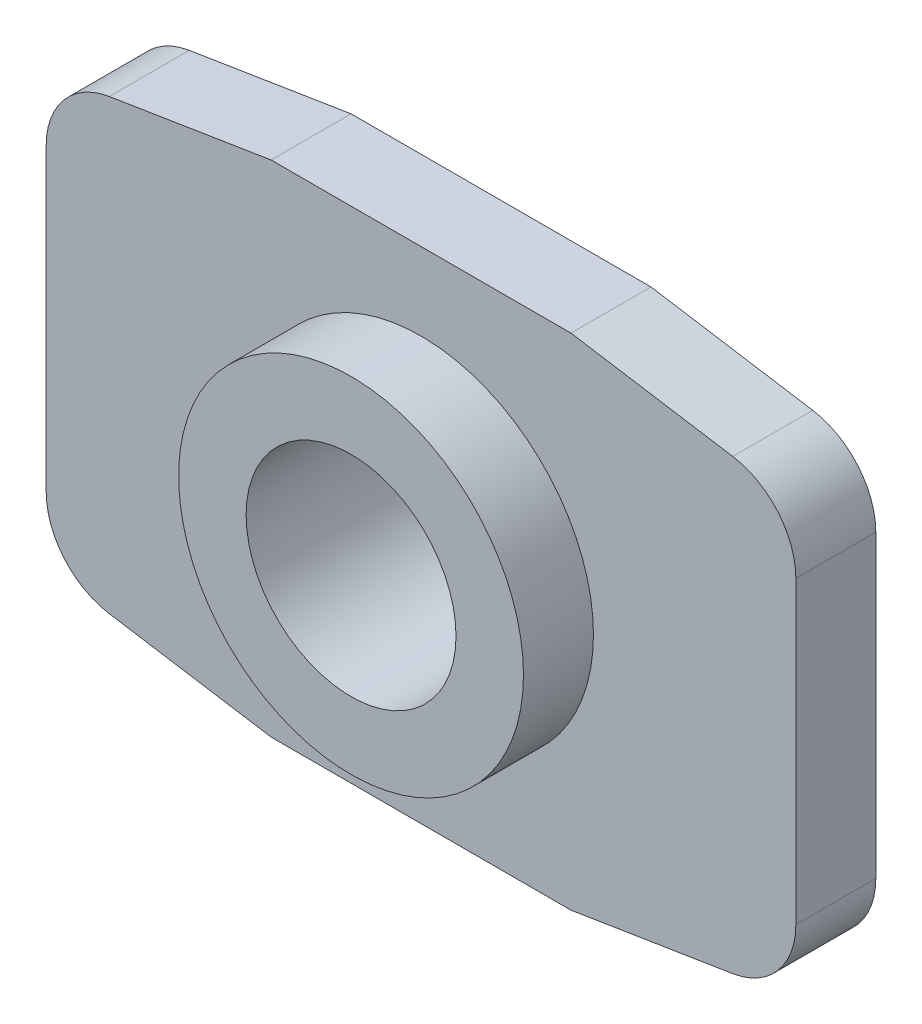
from build123d import *

# Parameters (mm, degrees)
BOSS_EXTRUDE1_DEPTH   = 1.6
SKETCH2_R             = 3.45
BOSS_EXTRUDE2_DEPTH   = 1.4
M5X0_8_TAPPED_HOLE1_D = 4.2


with BuildPart() as part:
    # Sketch1 → Boss-Extrude1 (new body)
    with BuildSketch(Plane.XY):
        with BuildLine():
            Line((-6.237396753, 4.481095129), (-3, 5))
            Line((-3, 5), (3, 5))
            Line((3, 5), (6.237396753, 4.481095129))
            ThreePointArc((6.237396753, 4.481095129), (7.141511088, 3.973114811), (7.5, 3))
            Line((7.5, 3), (7.5, -3))
            ThreePointArc((7.5, -3), (7.141511088, -3.973114811), (6.237396753, -4.481095129))
            Line((6.237396753, -4.481095129), (3, -5))
            Line((3, -5), (-3, -5))
            Line((-3, -5), (-6.237396753, -4.481095129))
            ThreePointArc((-6.237396753, -4.481095129), (-7.141511088, -3.973114811), (-7.5, -3))
            Line((-7.5, -3), (-7.5, 3))
            ThreePointArc((-7.5, 3), (-7.141511088, 3.973114811), (-6.237396753, 4.481095129))
        make_face()
    extrude(amount=BOSS_EXTRUDE1_DEPTH)

    # Sketch2 → Boss-Extrude2 (add)
    with BuildSketch(Plane.XY.offset(1.6)):
        Circle(SKETCH2_R)
    extrude(amount=BOSS_EXTRUDE2_DEPTH)

    # M5x0.8 Tapped Hole1 (through all)
    with Locations(Plane.XY.offset(3)):
        with Locations((0, 0)):
            Hole(M5X0_8_TAPPED_HOLE1_D / 2)


solid = part.part
